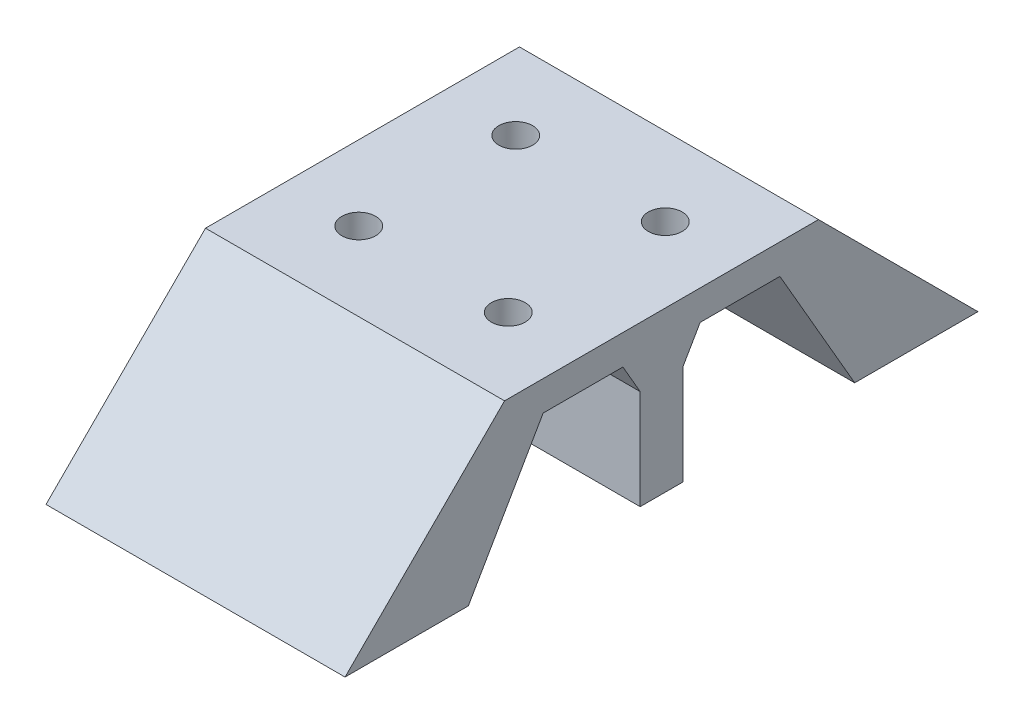
from build123d import *

# Parameters (mm, degrees)
BODY_DEPTH                           = 38.1
F_13_64_0_20313_DIAMETER_HOLE1_D     = 5.159502
F_13_64_0_20313_DIAMETER_HOLE1_DEPTH = 3.556
F_13_64_0_20313_DIAMETER_HOLE1_TIP   = 1.550070783
CHAMFER1_SIZE                        = 0.635
CHAMFER1_SIZE2                       = 0.366617421
CHAMFER1_PART_2_SIZE                 = 0.635
CHAMFER1_PART_2_SIZE2                = 0.366617421


with BuildPart() as part:
    # Profile → Body (new body)
    with BuildSketch(Plane(origin=(0, 0, 0), x_dir=(0, 0, -1), z_dir=(1, 0, 0))):
        Polygon((20, 1.905), (-20, 1.905), (-23.81, -1.905), (-27.62, -5.715), (-35.24, -13.335), (-40.32, -18.415), (-24.612052944, -18.415), (-21.679113577, -13.335), (-17.279704526, -5.715), (-15.08, -1.905), (-14.6, -1.905), (-5.4, -1.905), (-4.92, -1.905), (-2.720295474, -5.715), (-2.720295474, -13.335), (-2.720295474, -18.415), (2.720295474, -18.415), (2.720295474, -13.335), (2.720295474, -5.715), (4.92, -1.905), (5.4, -1.905), (14.6, -1.905), (15.08, -1.905), (17.279704526, -5.715), (21.679113577, -13.335), (24.612052944, -18.415), (40.32, -18.415), (35.24, -13.335), (27.62, -5.715), (23.81, -1.905), align=None)
    extrude(amount=BODY_DEPTH)

    # 13/64 (0.20313) Diameter Hole1
    with Locations(Plane(origin=(0, -1.905, 0), x_dir=(-1, 0, 0), z_dir=(0, -1, 0))):
        with Locations((-9.525, 10), (-9.525, -10), (-28.575, -10), (-28.575, 10)):
            Hole(F_13_64_0_20313_DIAMETER_HOLE1_D / 2, depth=F_13_64_0_20313_DIAMETER_HOLE1_DEPTH)
            with Locations((0, 0, -(F_13_64_0_20313_DIAMETER_HOLE1_DEPTH + F_13_64_0_20313_DIAMETER_HOLE1_TIP / 2))):  # 118° drill point
                Cone(0, F_13_64_0_20313_DIAMETER_HOLE1_D / 2, F_13_64_0_20313_DIAMETER_HOLE1_TIP, mode=Mode.SUBTRACT)

    # Chamfer1
    chamfer1_edges = [part.edges().sort_by_distance(p)[0] for p in [
        (25.995249, -1.905, -10),
        (6.945249, -1.905, -10),
    ]]
    chamfer1_side = [part.faces().sort_by_distance(p)[0] for p in [
        (19.05, -1.905, -10),
    ]]
    chamfer(chamfer1_edges, length=CHAMFER1_SIZE, length2=CHAMFER1_SIZE2, reference=chamfer1_side[0])

    # Chamfer1 part 2
    chamfer1_part_2_edges = [part.edges().sort_by_distance(p)[0] for p in [
        (25.995249, -1.905, 10),
        (6.945249, -1.905, 10),
    ]]
    chamfer1_part_2_side = [part.faces().sort_by_distance(p)[0] for p in [
        (19.05, -1.905, 10),
    ]]
    chamfer(chamfer1_part_2_edges, length=CHAMFER1_PART_2_SIZE, length2=CHAMFER1_PART_2_SIZE2, reference=chamfer1_part_2_side[0])


solid = part.part
